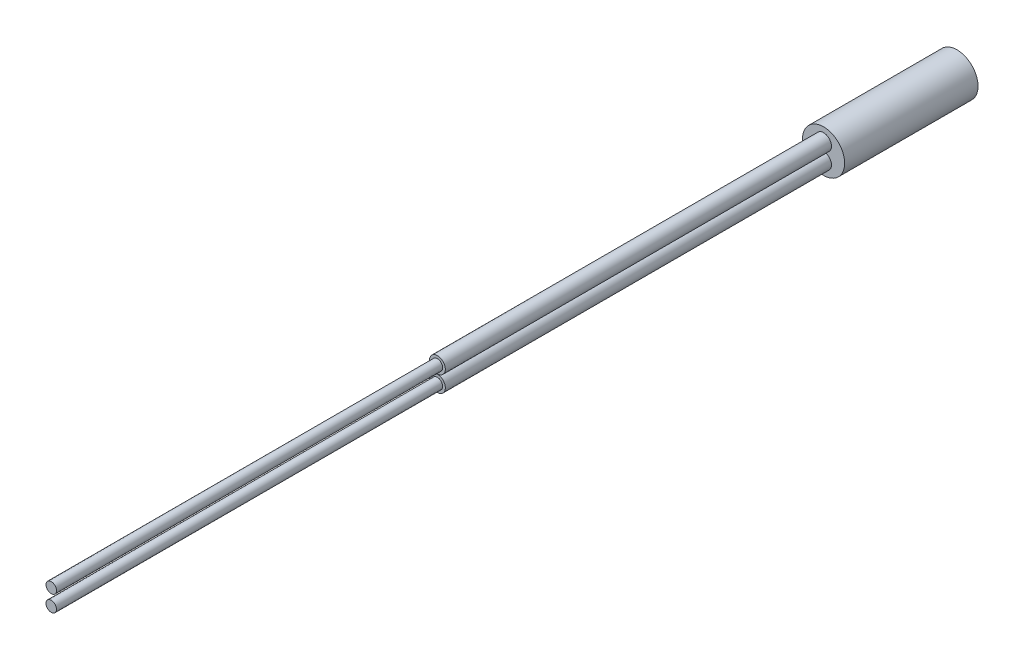
from build123d import *

# Parameters (mm, degrees)
CROQUIS1_R                   = 3
SALIENTE_EXTRUIR1_DEPTH      = 18
SALIENTE_EXTRUIR2_DEPTH      = 21.5
SALIENTE_EXTRUIR2_DEPTH_BACK = 1.5
CROQUIS1_2_R                 = 3
CROQUIS3_R                   = 3
CORTAR_EXTRUIR1_DEPTH        = 4
CROQUIS9_R                   = 1.125
SALIENTE_EXTRUIR3_DEPTH      = 55
CROQUIS10_R                  = 0.75
SALIENTE_EXTRUIR4_DEPTH      = 110


with BuildPart() as part:
    # Croquis1 → Saliente-Extruir1 (new body)
    with BuildSketch(Plane.XY):
        Circle(CROQUIS1_R)
    extrude(amount=SALIENTE_EXTRUIR1_DEPTH)

    # Croquis1_2 → Saliente-Extruir2 (add, two sides: drawn at the far end of the back side and taken through both)
    with BuildSketch(Plane.XY.offset(-SALIENTE_EXTRUIR2_DEPTH_BACK)):
        Circle(CROQUIS1_2_R)
    extrude(amount=SALIENTE_EXTRUIR2_DEPTH + SALIENTE_EXTRUIR2_DEPTH_BACK)

    # Croquis3 → Cortar-Extruir1 (cut)
    with BuildSketch(Plane(origin=(0, 0, -1.5), x_dir=(-1, 0, 0), z_dir=(0, 0, -1))):
        Circle(CROQUIS3_R)
    extrude(amount=-CORTAR_EXTRUIR1_DEPTH, mode=Mode.SUBTRACT)

    # Croquis9 → Saliente-Extruir3 (add)
    with BuildSketch(Plane.XY.offset(21.5)):
        with Locations((0, -1.15)):
            Circle(CROQUIS9_R)
        with Locations((0, 1.15)):
            Circle(CROQUIS9_R)
    extrude(amount=SALIENTE_EXTRUIR3_DEPTH)

    # Croquis10 → Saliente-Extruir4 (add)
    with BuildSketch(Plane.XY.offset(21.5)):
        with Locations((0, -1.15)):
            Circle(CROQUIS10_R)
        with Locations((0, 1.15)):
            Circle(CROQUIS10_R)
    extrude(amount=SALIENTE_EXTRUIR4_DEPTH)


solid = part.part
